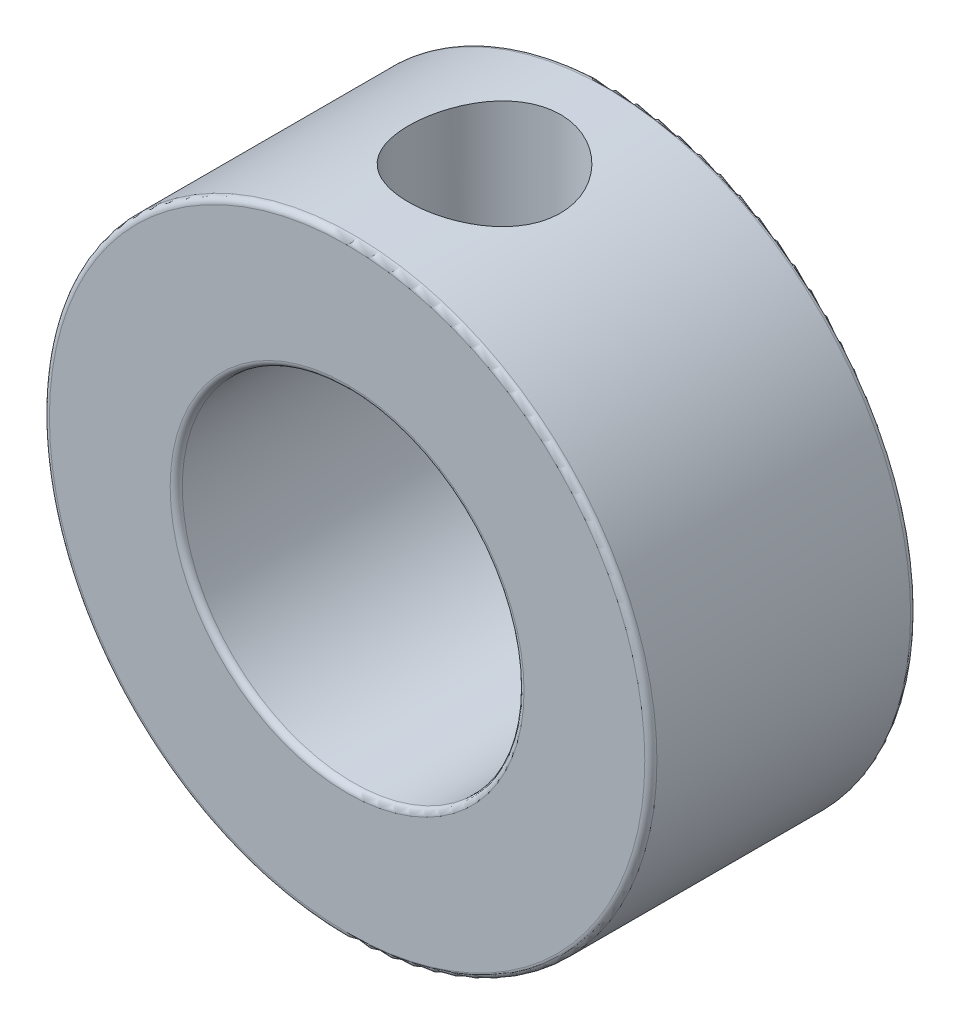
from build123d import *

# Parameters (mm, degrees)
SKETCH1_R                       = 12.7
SKETCH1_R_2                     = 7.14375
BOSS_EXTRUDE1_DEPTH             = 11.1125
FILLET1_R                       = 0.254
F_1_4_0_25_DIAMETER_HOLE1_D     = 6.35
F_1_4_0_25_DIAMETER_HOLE1_DEPTH = 10.922
F_1_4_0_25_DIAMETER_HOLE1_TIP   = 1.907732465


with BuildPart() as part:
    # Sketch1 → Boss-Extrude1 (new body)
    with BuildSketch(Plane.XY):
        Circle(SKETCH1_R)
        Circle(SKETCH1_R_2, mode=Mode.SUBTRACT)
    extrude(amount=BOSS_EXTRUDE1_DEPTH)

    # Fillet1
    fillet1_edges = [part.edges().sort_by_distance(p)[0] for p in [
        (-12.7, 0, 0),
        (-12.7, 0, 11.1125),
        (-7.14375, 0, 0),
        (-7.14375, 0, 11.1125),
    ]]
    fillet(fillet1_edges, radius=FILLET1_R)

    # 1/4 (0.25) Diameter Hole1
    with Locations(Plane(origin=(-0.017095138, 12.699988494, 5.351108343), x_dir=(0.999999094, 0.001346074, 0), z_dir=(-0.001346074, 0.999999094, 0))):
        with Locations((0, 0)):
            Hole(F_1_4_0_25_DIAMETER_HOLE1_D / 2, depth=F_1_4_0_25_DIAMETER_HOLE1_DEPTH)
            with Locations((0, 0, -(F_1_4_0_25_DIAMETER_HOLE1_DEPTH + F_1_4_0_25_DIAMETER_HOLE1_TIP / 2))):  # 118° drill point
                Cone(0, F_1_4_0_25_DIAMETER_HOLE1_D / 2, F_1_4_0_25_DIAMETER_HOLE1_TIP, mode=Mode.SUBTRACT)


solid = part.part
